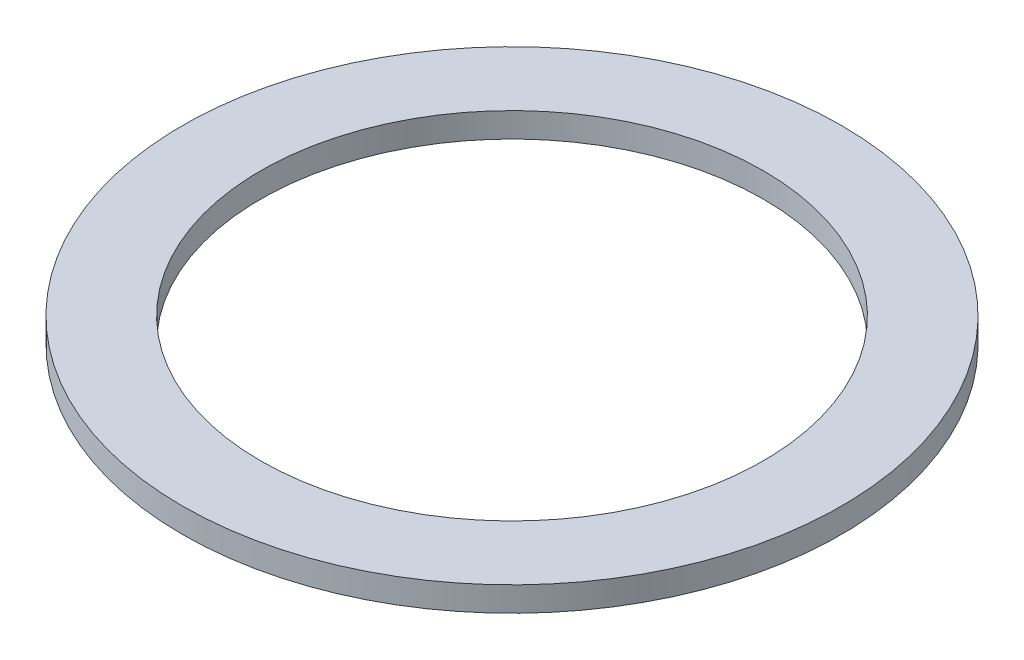
from build123d import *

# Parameters (mm, degrees)
SKETCH1_R           = 6.7945
SKETCH1_R_2         = 5.1816
BOSS_EXTRUDE1_DEPTH = 0.508


with BuildPart() as part:
    # Sketch1 → Boss-Extrude1 (new body)
    with BuildSketch(Plane(origin=(0, 0, 0), x_dir=(1, 0, 0), z_dir=(0, 1, 0))):
        Circle(SKETCH1_R)
        Circle(SKETCH1_R_2, mode=Mode.SUBTRACT)
    extrude(amount=BOSS_EXTRUDE1_DEPTH)


solid = part.part
